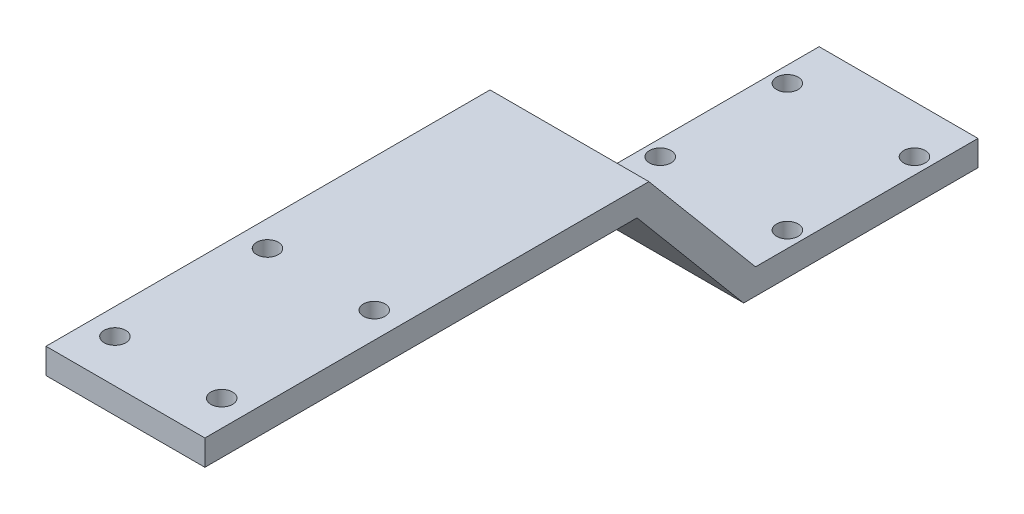
from build123d import *

# Parameters (mm, degrees)
BOSS_EXTRUDE1_DEPTH      = 12.5
M3_CLEARANCE_HOLE1_D     = 3.4
M3_CLEARANCE_HOLE1_DEPTH = 8.5
M3_CLEARANCE_HOLE1_TIP   = 1.021463052
M3_CLEARANCE_HOLE2_D     = 3.4
M3_CLEARANCE_HOLE2_DEPTH = 8.5
M3_CLEARANCE_HOLE2_TIP   = 1.021463052


with BuildPart() as part:
    # Sketch2 → Boss-Extrude1 (new body, symmetric)
    with BuildSketch(Plane(origin=(0, 0, 0), x_dir=(0, 0, -1), z_dir=(1, 0, 0))):
        Polygon((0, 0), (0, 4), (-35, 4), (-51.781992624, 24), (-121.647223256, 24), (-121.647223256, 20), (-53.647223256, 20), (-36.865230633, 0), align=None)
    extrude(amount=BOSS_EXTRUDE1_DEPTH, both=True)

    # M3 Clearance Hole1
    with Locations(Plane(origin=(0, 24, 0), x_dir=(1, 0, 0), z_dir=(0, 1, 0))):
        with Locations((-8.4, -90.897223256), (-8.4, -114.897223256), (8.4, -114.897223256), (8.4, -90.897223256)):
            Hole(M3_CLEARANCE_HOLE1_D / 2, depth=M3_CLEARANCE_HOLE1_DEPTH)
            with Locations((0, 0, -(M3_CLEARANCE_HOLE1_DEPTH + M3_CLEARANCE_HOLE1_TIP / 2))):  # 118° drill point
                Cone(0, M3_CLEARANCE_HOLE1_D / 2, M3_CLEARANCE_HOLE1_TIP, mode=Mode.SUBTRACT)

    # M3 Clearance Hole2
    with Locations(Plane(origin=(0, 4, 0), x_dir=(1, 0, 0), z_dir=(0, 1, 0))):
        with Locations((-10, -27.5), (10, -27.5), (10, -7.5), (-10, -7.5)):
            Hole(M3_CLEARANCE_HOLE2_D / 2, depth=M3_CLEARANCE_HOLE2_DEPTH)
            with Locations((0, 0, -(M3_CLEARANCE_HOLE2_DEPTH + M3_CLEARANCE_HOLE2_TIP / 2))):  # 118° drill point
                Cone(0, M3_CLEARANCE_HOLE2_D / 2, M3_CLEARANCE_HOLE2_TIP, mode=Mode.SUBTRACT)


solid = part.part
